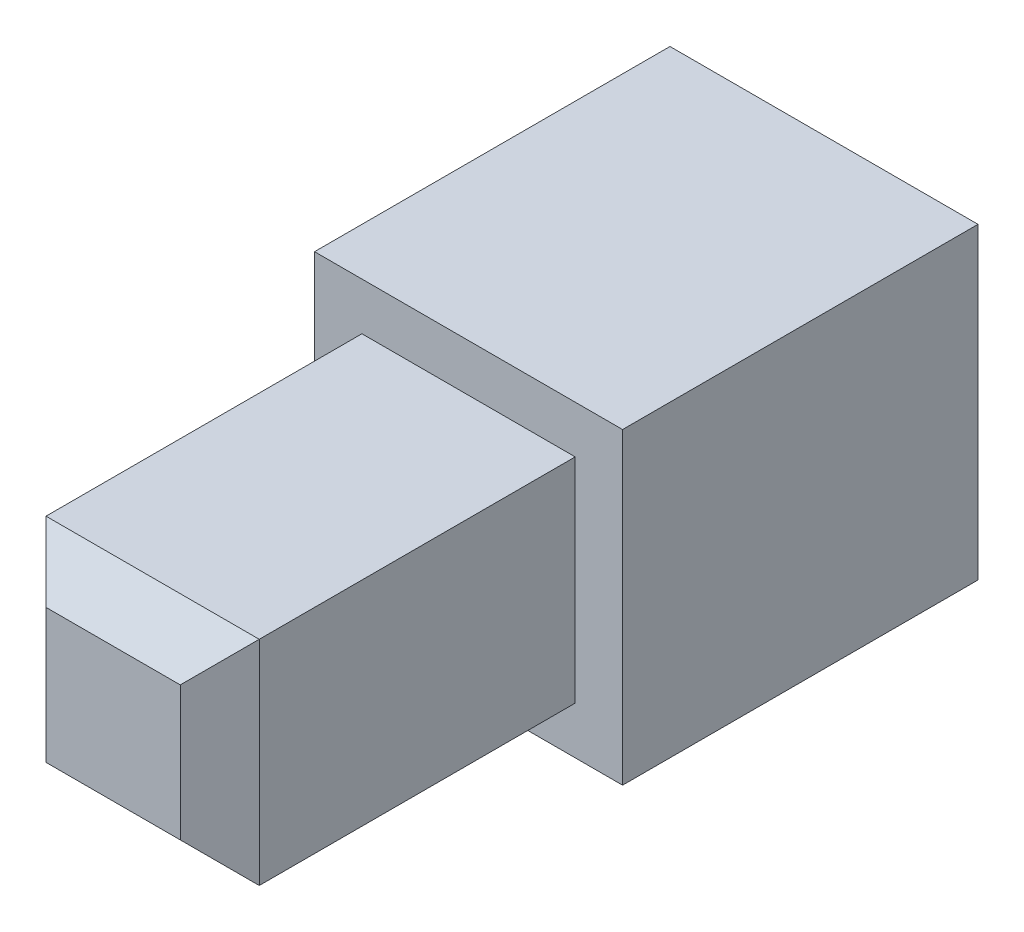
from build123d import *

# Parameters (mm, degrees)
SKETCH2_W           = 7.799999809
SKETCH2_H           = 7.79999981
BOSS_EXTRUDE1_DEPTH = 5
SKETCH3_W           = 7.799999809
SKETCH3_H           = 7.79999981
SKETCH3_W_2         = 6.199999809
SKETCH3_H_2         = 6.19999981
BOSS_EXTRUDE2_DEPTH = 4
SKETCH4_W           = 5.399999809
SKETCH4_H           = 5.39999981
BOSS_EXTRUDE3_DEPTH = 9
CHAMFER1_SIZE       = 1


with BuildPart() as part:
    # Sketch2 → Boss-Extrude1 (new body)
    with BuildSketch(Plane.XY.offset(100.335422766)):
        with Locations((-12.150804877, 90.015849294)):
            Rectangle(SKETCH2_W, SKETCH2_H)
    extrude(amount=BOSS_EXTRUDE1_DEPTH)

    # Sketch3 → Boss-Extrude2 (add)
    with BuildSketch(Plane(origin=(0, 0, 100.335422766), x_dir=(-1, 0, 0), z_dir=(0, 0, -1))):
        with Locations((12.150804877, 90.015849294)):
            Rectangle(SKETCH3_W, SKETCH3_H)
        with Locations((12.150804877, 90.015849294)):
            Rectangle(SKETCH3_W_2, SKETCH3_H_2, mode=Mode.SUBTRACT)
    extrude(amount=BOSS_EXTRUDE2_DEPTH)

    # Sketch4 → Boss-Extrude3 (add)
    with BuildSketch(Plane.XY.offset(105.335422766)):
        with Locations((-12.150804877, 90.015849294)):
            Rectangle(SKETCH4_W, SKETCH4_H)
    extrude(amount=BOSS_EXTRUDE3_DEPTH)

    # Chamfer1
    chamfer1_edges = [part.edges().sort_by_distance(p)[0] for p in [
        (-14.850804781, 90.015849294, 114.335422766),
        (-12.150804876, 87.315849389, 114.335422766),
        (-9.450804972, 90.015849294, 114.335422766),
        (-12.150804876, 92.715849199, 114.335422766),
    ]]
    chamfer(chamfer1_edges, length=CHAMFER1_SIZE)


solid = part.part
